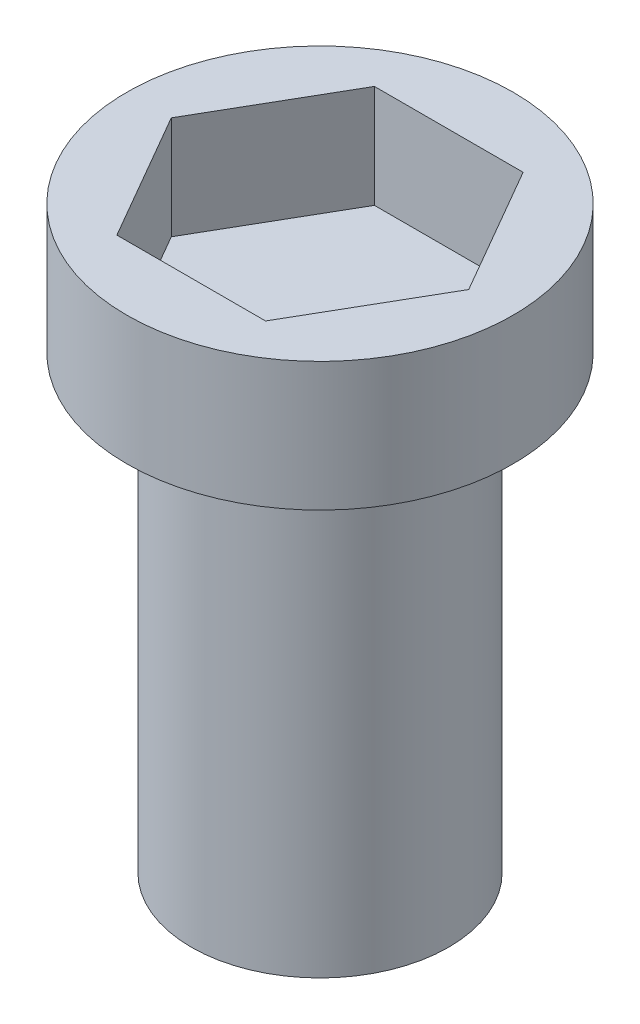
from build123d import *

# Parameters (mm, degrees)
SKETCH1_R           = 10
BOSS_EXTRUDE1_DEPTH = 35
SKETCH2_R           = 15
BOSS_EXTRUDE2_DEPTH = 10
BOSS_EXTRUDE3_DEPTH = 2


with BuildPart() as part:
    # Sketch1 → Boss-Extrude1 (new body)
    with BuildSketch(Plane(origin=(0, 0, 0), x_dir=(1, 0, 0), z_dir=(0, 1, 0))):
        Circle(SKETCH1_R)
    extrude(amount=BOSS_EXTRUDE1_DEPTH)



with BuildPart() as body_2:
    # Sketch2 → Boss-Extrude2 (new body)
    with BuildSketch(Plane(origin=(0, 35, 0), x_dir=(1, 0, 0), z_dir=(0, 1, 0))):
        Circle(SKETCH2_R)
        Polygon((11.547005384, 0), (5.773502692, 10), (-5.773502692, 10), (-11.547005384, 0), (-5.773502692, -10), (5.773502692, -10), align=None, mode=Mode.SUBTRACT)
    extrude(amount=BOSS_EXTRUDE2_DEPTH)


with BuildPart() as part_1:
    add(part.part)

    add(body_2.part)  # Boss-Extrude3 merges body 2
    # Sketch3 → Boss-Extrude3 (add)
    with BuildSketch(Plane(origin=(0, 35, 0), x_dir=(1, 0, 0), z_dir=(0, 1, 0))):
        Polygon((11.547005384, 0), (5.773502692, 10), (-5.773502692, 10), (-11.547005384, 0), (-5.773502692, -10), (5.773502692, -10), align=None)
    extrude(amount=BOSS_EXTRUDE3_DEPTH)


solid = part_1.part
